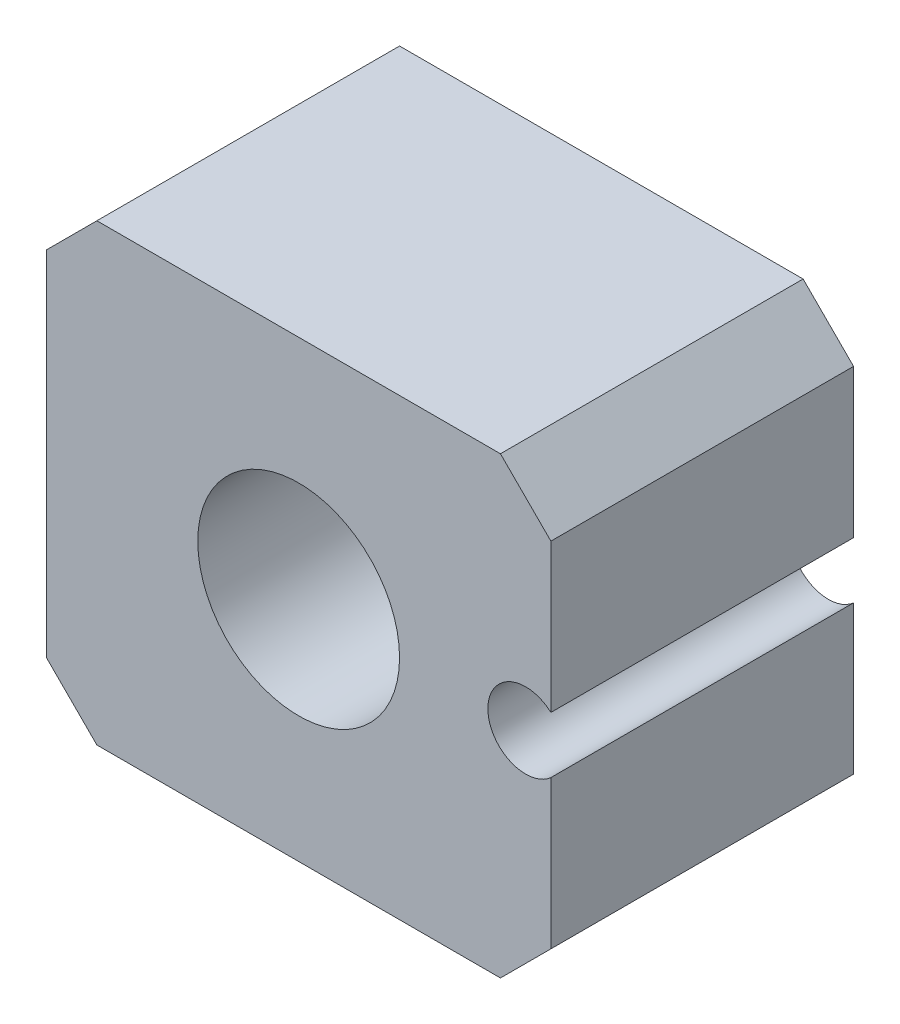
from build123d import *

# Parameters (mm, degrees)
SKETCH1_W           = 20
SKETCH1_H           = 18
BOSS_EXTRUDE1_DEPTH = 12
SKETCH2_R           = 1.5
SKETCH2_R_2         = 4
CUT_EXTRUDE1_DEPTH  = 13
CHAMFER1_SIZE       = 2


with BuildPart() as part:
    # Sketch1 → Boss-Extrude1 (new body)
    with BuildSketch(Plane.XY):
        Rectangle(SKETCH1_W, SKETCH1_H)
    extrude(amount=BOSS_EXTRUDE1_DEPTH)

    # Sketch2 → Cut-Extrude1 (cut, through all)
    with BuildSketch(Plane.XY.offset(12)):
        with Locations((9, 0)):
            Circle(SKETCH2_R)
        Circle(SKETCH2_R_2)
    extrude(amount=-CUT_EXTRUDE1_DEPTH, mode=Mode.SUBTRACT)

    # Chamfer1
    chamfer1_edges = [part.edges().sort_by_distance(p)[0] for p in [
        (10, 9, 6),
        (10, -9, 6),
        (-10, -9, 6),
        (-10, 9, 6),
    ]]
    chamfer(chamfer1_edges, length=CHAMFER1_SIZE)


solid = part.part
